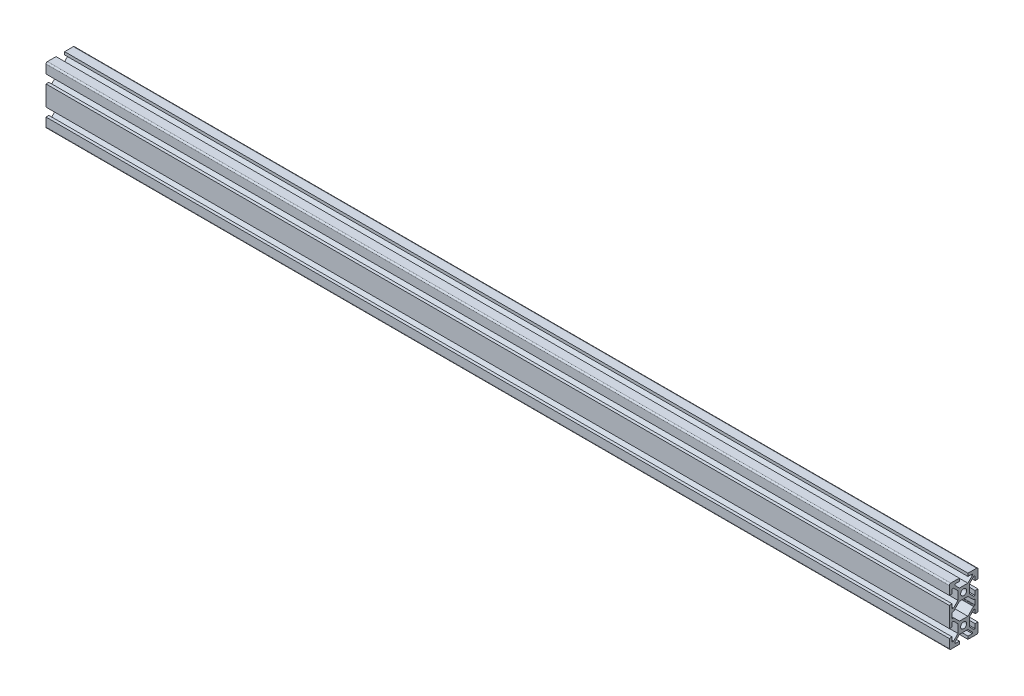
from build123d import *

# Parameters (mm, degrees)
SKETCH1_R           = 2.1
BOSS_EXTRUDE1_DEPTH = 630


with BuildPart() as part:
    # Sketch1 → Boss-Extrude1 (new body)
    with BuildSketch(Plane(origin=(0, 0, 0), x_dir=(0, 0, -1), z_dir=(1, 0, 0))):
        with BuildLine():
            Line((-10, -13), (-10, -19))
            ThreePointArc((-10, -19), (-9.707106781, -19.707106781), (-9, -20))
            Line((-9, -20), (-3, -20))
            Line((-3, -20), (-3, -18))
            Line((-3, -18), (-6, -18))
            Line((-6, -18), (-6, -17.060660172))
            Line((-6, -17.060660172), (-2.939339828, -14))
            Line((-2.939339828, -14), (2.939339828, -14))
            Line((2.939339828, -14), (6, -17.060660172))
            Line((6, -17.060660172), (6, -18))
            Line((6, -18), (3, -18))
            Line((3, -18), (3, -20))
            Line((3, -20), (9, -20))
            ThreePointArc((9, -20), (9.707106781, -19.707106781), (10, -19))
            Line((10, -19), (10, -13))
            Line((10, -13), (8, -13))
            Line((8, -13), (8, -16))
            Line((8, -16), (7.060660172, -16))
            Line((7.060660172, -16), (4, -12.939339828))
            Line((4, -12.939339828), (4, -7.060660172))
            Line((4, -7.060660172), (7.060660172, -4))
            Line((7.060660172, -4), (8, -4))
            Line((8, -4), (8, -7))
            Line((8, -7), (10, -7))
            Line((10, -7), (10, 7))
            Line((10, 7), (8, 7))
            Line((8, 7), (8, 4))
            Line((8, 4), (7.060660172, 4))
            Line((7.060660172, 4), (4, 7.060660172))
            Line((4, 7.060660172), (4, 12.939339828))
            Line((4, 12.939339828), (7.060660172, 16))
            Line((7.060660172, 16), (8, 16))
            Line((8, 16), (8, 13))
            Line((8, 13), (10, 13))
            Line((10, 13), (10, 19))
            ThreePointArc((10, 19), (9.707106781, 19.707106781), (9, 20))
            Line((9, 20), (3, 20))
            Line((3, 20), (3, 18))
            Line((3, 18), (6, 18))
            Line((6, 18), (6, 17.060660172))
            Line((6, 17.060660172), (2.939339828, 14))
            Line((2.939339828, 14), (-2.939339828, 14))
            Line((-2.939339828, 14), (-6, 17.060660172))
            Line((-6, 17.060660172), (-6, 18))
            Line((-6, 18), (-3, 18))
            Line((-3, 18), (-3, 20))
            Line((-3, 20), (-9, 20))
            ThreePointArc((-9, 20), (-9.707106781, 19.707106781), (-10, 19))
            Line((-10, 19), (-10, 13))
            Line((-10, 13), (-8, 13))
            Line((-8, 13), (-8, 16))
            Line((-8, 16), (-7.060660172, 16))
            Line((-7.060660172, 16), (-4, 12.939339828))
            Line((-4, 12.939339828), (-4, 7.060660172))
            Line((-4, 7.060660172), (-7.060660172, 4))
            Line((-7.060660172, 4), (-8, 4))
            Line((-8, 4), (-8, 7))
            Line((-8, 7), (-10, 7))
            Line((-10, 7), (-10, -7))
            Line((-10, -7), (-8, -7))
            Line((-8, -7), (-8, -4))
            Line((-8, -4), (-7.060660172, -4))
            Line((-7.060660172, -4), (-4, -7.060660172))
            Line((-4, -7.060660172), (-4, -12.939339828))
            Line((-4, -12.939339828), (-7.060660172, -16))
            Line((-7.060660172, -16), (-8, -16))
            Line((-8, -16), (-8, -13))
            Line((-8, -13), (-10, -13))
        make_face()
        with Locations((0, 10)):
            Circle(SKETCH1_R, mode=Mode.SUBTRACT)
        with Locations((0, -10)):
            Circle(SKETCH1_R, mode=Mode.SUBTRACT)
        with BuildLine():
            Line((-8, 1.7), (-8, -1.7))
            ThreePointArc((-8, -1.7), (-7.912132034, -1.912132034), (-7.7, -2))
            Line((-7.7, -2), (-7.063603897, -2))
            ThreePointArc((-7.063603897, -2), (-6.948798867, -2.02283614), (-6.851471863, -2.087867966))
            Line((-6.851471863, -2.087867966), (-2.939339828, -6))
            Line((-2.939339828, -6), (2.939339828, -6))
            Line((2.939339828, -6), (6.851471863, -2.087867966))
            ThreePointArc((6.851471863, -2.087867966), (6.948798867, -2.02283614), (7.063603897, -2))
            Line((7.063603897, -2), (7.7, -2))
            ThreePointArc((7.7, -2), (7.912132034, -1.912132034), (8, -1.7))
            Line((8, -1.7), (8, 1.7))
            ThreePointArc((8, 1.7), (7.912132034, 1.912132034), (7.7, 2))
            Line((7.7, 2), (7.063603897, 2))
            ThreePointArc((7.063603897, 2), (6.948798867, 2.02283614), (6.851471863, 2.087867966))
            Line((6.851471863, 2.087867966), (2.939339828, 6))
            Line((2.939339828, 6), (-2.939339828, 6))
            Line((-2.939339828, 6), (-6.851471863, 2.087867966))
            ThreePointArc((-6.851471863, 2.087867966), (-6.948798867, 2.02283614), (-7.063603897, 2))
            Line((-7.063603897, 2), (-7.7, 2))
            ThreePointArc((-7.7, 2), (-7.912132034, 1.912132034), (-8, 1.7))
        make_face(mode=Mode.SUBTRACT)
    extrude(amount=BOSS_EXTRUDE1_DEPTH)


solid = part.part
